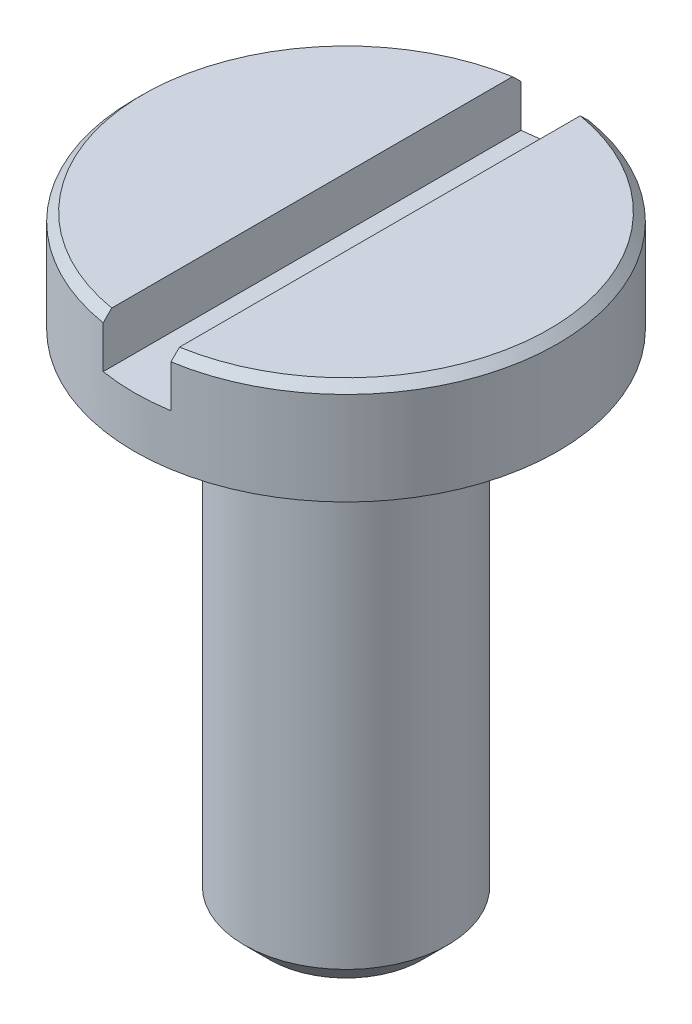
from build123d import *

# Parameters (mm, degrees)
SKETCH1_R               = 1.25
BOSS_EXTRUDE1_DEPTH     = 0.6
SKETCH2_R               = 0.6
BOSS_EXTRUDE2_DEPTH     = 3
CHAMFER1_SIZE           = 0.05
CHAMFER2_SIZE           = 0.15
CUT_EXTRUDE1_DEPTH      = 2.25
CUT_EXTRUDE1_DEPTH_BACK = 2.25


with BuildPart() as part:
    # Sketch1 → Boss-Extrude1 (new body)
    with BuildSketch(Plane(origin=(0, 0, 0), x_dir=(1, 0, 0), z_dir=(0, 1, 0))):
        Circle(SKETCH1_R)
    extrude(amount=BOSS_EXTRUDE1_DEPTH)

    # Sketch2 → Boss-Extrude2 (add)
    with BuildSketch(Plane(origin=(0, 0, 0), x_dir=(1, 0, 0), z_dir=(0, 1, 0))):
        Circle(SKETCH2_R)
    extrude(amount=-BOSS_EXTRUDE2_DEPTH)

    # Chamfer1
    chamfer1_edges = [part.edges().sort_by_distance(p)[0] for p in [
        (-1.25, 0.6, 0),
    ]]
    chamfer(chamfer1_edges, length=CHAMFER1_SIZE)

    # Chamfer2
    chamfer2_edges = [part.edges().sort_by_distance(p)[0] for p in [
        (-0.6, -3, 0),
    ]]
    chamfer(chamfer2_edges, length=CHAMFER2_SIZE)

    # Sketch3 → Cut-Extrude1 (cut, two sides)
    with BuildSketch(Plane.XY) as cut_extrude1_sk:
        Polygon((-0.2, 0.6), (0, 0.6), (0.2, 0.6), (0.2, 0.3), (0, 0.3), (-0.2, 0.3), align=None)
    extrude(amount=CUT_EXTRUDE1_DEPTH, mode=Mode.SUBTRACT)
    extrude(cut_extrude1_sk.sketch, amount=-CUT_EXTRUDE1_DEPTH_BACK, mode=Mode.SUBTRACT)


solid = part.part
